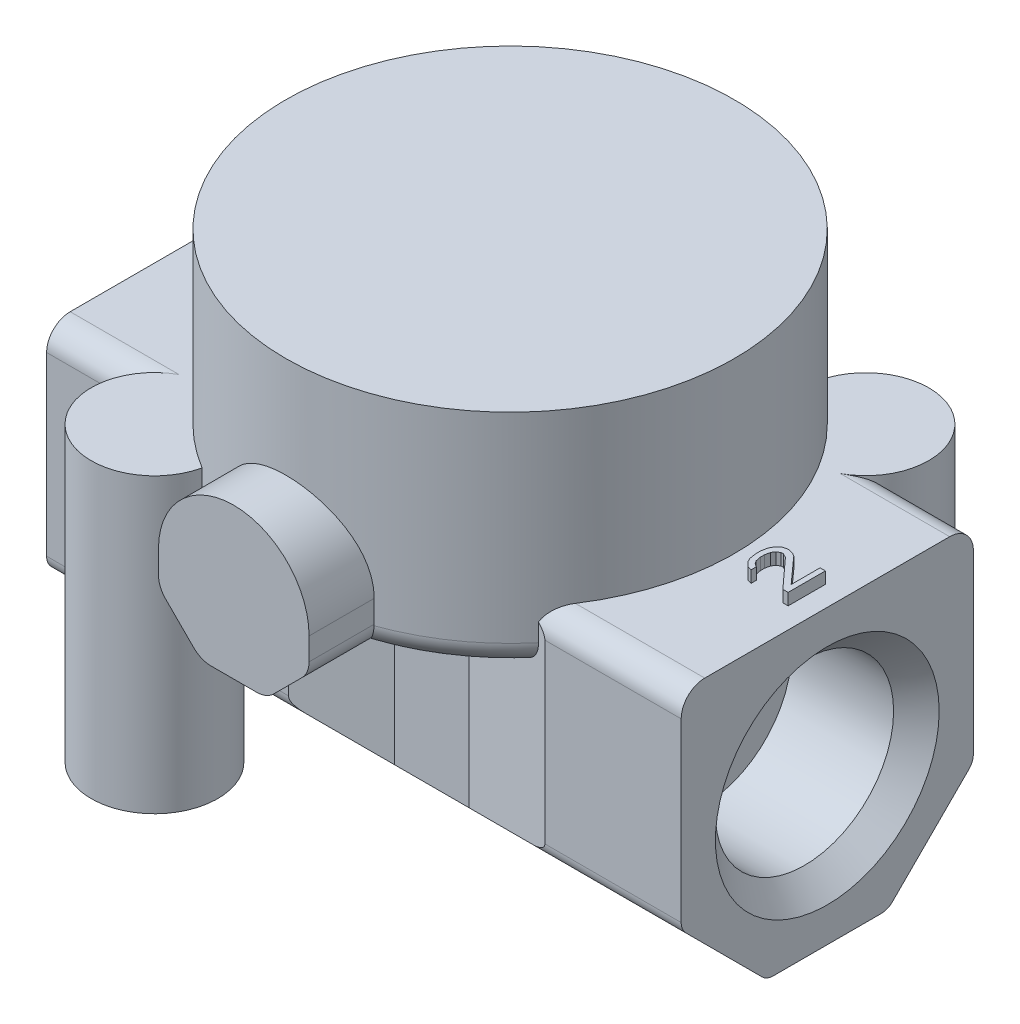
from build123d import *

# Parameters (mm, degrees)
BOSS_EXTRUDE1_DEPTH      = 39.612
CUT_EXTRUDE1_DEPTH       = 5.547196
CUT_EXTRUDE1_DEPTH_BACK  = 5.547196
SKETCH3_W                = 84.337272
SKETCH3_H                = 65.415448
CUT_EXTRUDE2_DEPTH       = 8.27616
CUT_EXTRUDE2_DEPTH_BACK  = 8.27616
SKETCH5_R                = 3.95
BOSS_EXTRUDE2_DEPTH      = 18.269694
BOSS_EXTRUDE3_DEPTH      = 20
SKETCH7_R                = 3.937
BOSS_EXTRUDE4_DEPTH      = 18.269694
BOSS_EXTRUDE5_DEPTH      = 0.7
BOSS_EXTRUDE5_DEPTH_BACK = 0.7
BOSS_EXTRUDE6_DEPTH      = 0.7
BOSS_EXTRUDE6_DEPTH_BACK = 0.7


with BuildPart() as part:
    # Sketch1 → Boss-Extrude1 (new body)
    with BuildSketch(Plane(origin=(19.8, 0, 0), x_dir=(0, 0, -1), z_dir=(1, 0, 0))):
        with BuildLine():
            Line((-8.826801, -4.086395), (-4.070394, -8.842802))
            ThreePointArc((-4.070394, -8.842802), (-3.745971, -9.059574), (-3.363288, -9.135695))
            Line((-3.363288, -9.135695), (3.363288, -9.135695))
            ThreePointArc((3.363288, -9.135695), (3.745971, -9.059574), (4.070395, -8.842801))
            Line((4.070395, -8.842801), (8.826802, -4.086394))
            ThreePointArc((8.826802, -4.086394), (9.043574, -3.761971), (9.119695, -3.379287))
            Line((9.119695, -3.379287), (9.119694, 7.624))
            ThreePointArc((9.119694, 7.624), (8.686302, 8.670302), (7.64, 9.103694))
            Line((7.64, 9.103694), (-7.65, 9.103694))
            ThreePointArc((-7.65, 9.103694), (-8.68923, 8.673231), (-9.119694, 7.634))
            Line((-9.119694, 7.634), (-9.119695, -3.379288))
            ThreePointArc((-9.119695, -3.379288), (-9.043574, -3.761971), (-8.826801, -4.086395))
        make_face()
    extrude(amount=-BOSS_EXTRUDE1_DEPTH)

    # Sketch2 → Cut-Extrude1 (cut, two sides)
    with BuildSketch(Plane.XY) as cut_extrude1_sk:
        Polygon((-11.4, -16.447815), (11.4, -16.447815), (11.4, -9.166), (4.8, -7.366), (-4.8, -7.366), (-11.4, -9.166), align=None)
    extrude(amount=CUT_EXTRUDE1_DEPTH, mode=Mode.SUBTRACT)
    extrude(cut_extrude1_sk.sketch, amount=-CUT_EXTRUDE1_DEPTH_BACK, mode=Mode.SUBTRACT)

    # Sketch3 → Cut-Extrude2 (cut, two sides)
    with BuildSketch(Plane(origin=(0, 0, 0), x_dir=(1, 0, 0), z_dir=(0, 1, 0))) as cut_extrude2_sk:
        with Locations((0.851815, -0.975045)):
            Rectangle(SKETCH3_W, SKETCH3_H)
        Polygon((-26.15286, 16.921805), (-26.15286, -16.921805), (0.145459, -7.35), (4.8, -7.35), (30.199192, -14.277052), (30.199192, 14.277052), (4.8, 7.35), (0.145459, 7.35), align=None, mode=Mode.SUBTRACT)
    extrude(amount=CUT_EXTRUDE2_DEPTH, mode=Mode.SUBTRACT)
    extrude(cut_extrude2_sk.sketch, amount=-CUT_EXTRUDE2_DEPTH_BACK, mode=Mode.SUBTRACT)

    # Sketch4 → Revolve1 (revolve)
    with BuildSketch(Plane(origin=(0, 0, 0), x_dir=(0, 0, -1), z_dir=(1, 0, 0))):
        with BuildLine():
            Line((0, 19.65), (14, 19.65))
            Line((14, 19.65), (14, 7.15))
            ThreePointArc((14, 7.15), (13.56066, 6.08934), (12.5, 5.65))
            Line((12.5, 5.65), (0, 5.65))
            Line((0, 5.65), (0, 19.65))
        make_face()
    revolve(axis=Axis((0, 5.65, 0), (0, 1, 0)))

    # Sketch5 → Boss-Extrude2 (add)
    with BuildSketch(Plane(origin=(0, -9.166, 0), x_dir=(-1, 0, 0), z_dir=(0, -1, 0))):
        with Locations((11.1, -11.1)):
            Circle(SKETCH5_R)
    extrude(amount=-BOSS_EXTRUDE2_DEPTH)

    # Sketch6 → Boss-Extrude3 (add)
    with BuildSketch(Plane.XY.offset(17.25)):
        with BuildLine():
            Line((-4.7, 8.63), (-4.7, 7.231261))
            ThreePointArc((-4.7, 7.231261), (-4.583992, 6.648052), (-4.253631, 6.153631))
            Line((-4.253631, 6.153631), (-2.496369, 4.396369))
            ThreePointArc((-2.496369, 4.396369), (-2.001948, 4.066008), (-1.418739, 3.95))
            Line((-1.418739, 3.95), (1.418739, 3.95))
            ThreePointArc((1.418739, 3.95), (2.001948, 4.066008), (2.496369, 4.396369))
            Line((2.496369, 4.396369), (4.253631, 6.153631))
            ThreePointArc((4.253631, 6.153631), (4.583992, 6.648052), (4.7, 7.231261))
            Line((4.7, 7.231261), (4.7, 8.63))
            ThreePointArc((4.7, 8.63), (0, 13.350043), (-4.7, 8.63))
        make_face()
    extrude(amount=-BOSS_EXTRUDE3_DEPTH)

    # Sketch7 → Boss-Extrude4 (add)
    with BuildSketch(Plane(origin=(0, -9.166, 0), x_dir=(-1, 0, 0), z_dir=(0, -1, 0))):
        with Locations((-11.1, 11.1)):
            Circle(SKETCH7_R)
    extrude(amount=-BOSS_EXTRUDE4_DEPTH)

    # Sketch8 → Boss-Extrude5 (add, two sides)
    with BuildSketch(Plane(origin=(0, 9.134, 0), x_dir=(1, 0, 0), z_dir=(0, 1, 0))) as boss_extrude5_sk:
        Polygon((-15.2, -0.265), (-15.2, 0.1225), (-15.661702, 0.51), (-16.189362, 0.51), (-15.72766, 0.1225), (-18.3, 0.1225), (-18.3, -0.265), align=None)
    extrude(amount=BOSS_EXTRUDE5_DEPTH)
    extrude(boss_extrude5_sk.sketch, amount=-BOSS_EXTRUDE5_DEPTH_BACK)

    # Sketch9 → Boss-Extrude6 (add, two sides)
    with BuildSketch(Plane(origin=(0, 9.134, 0), x_dir=(1, 0, 0), z_dir=(0, 1, 0))) as boss_extrude6_sk:
        Polygon((18.5, -1.143), (18.5, 1.182), (18.170213, 1.182), (18.170213, -0.626333), (16.719149, 0.98825), (16.521277, 1.117417), (16.257447, 1.182), (16.125532, 1.182), (15.861702, 1.117417), (15.597872, 0.859083), (15.465957, 0.60075), (15.4, 0.21325), (15.4, -0.045083), (15.465957, -0.497167), (15.597872, -0.7555), (15.861702, -1.013833), (16.125532, -1.078417), (16.125532, -0.7555), (15.92766, -0.626333), (15.795745, -0.432583), (15.729787, -0.109667), (15.729787, 0.148667), (15.795745, 0.471583), (15.92766, 0.665333), (16.125532, 0.7945), (16.257447, 0.7945), (16.521277, 0.665333), (18.170213, -1.143), align=None)
    extrude(amount=BOSS_EXTRUDE6_DEPTH)
    extrude(boss_extrude6_sk.sketch, amount=-BOSS_EXTRUDE6_DEPTH_BACK)

    # Sketch10 → Cut-Revolve1 (revolve, cut)
    with BuildSketch(Plane(origin=(0, 0, -11.1), x_dir=(-1, 0, 0), z_dir=(0, 0, -1))):
        Polygon((-11.1125, -9.166), (-13.97, -9.166), (-13.208, -8.404), (-13.208, 0.484), (-11.1125, 1.743103), align=None)
    revolve(axis=Axis((11.1125, 1.743207, -11.1), (0, -1, 0)), mode=Mode.SUBTRACT)

    # Sketch11 → Cut-Revolve2 (revolve, cut)
    with BuildSketch(Plane(origin=(0, 0, 11.1), x_dir=(-1, 0, 0), z_dir=(0, 0, -1))):
        Polygon((11.1125, -9.166), (8.317, -9.166), (9.0455, -8.4375), (9.0455, 0.501125), (11.1125, 1.743103), align=None)
    revolve(axis=Axis((-11.1125, 1.743207, 11.1), (0, -1, 0)), mode=Mode.SUBTRACT)

    # Sketch12 → Cut-Revolve3 (revolve, cut)
    with BuildSketch(Plane(origin=(0, 0, 0), x_dir=(-1, 0, 0), z_dir=(0, 0, -1))):
        Polygon((12, 0), (12, 5.4991), (18.3111, 5.4991), (19.812, 7), (19.812, 0), align=None)
    revolve(axis=Axis((-19.812, 0, 0), (1, 0, 0)), mode=Mode.SUBTRACT)

    # Sketch13 → Cut-Revolve4 (revolve, cut)
    with BuildSketch(Plane(origin=(0, 0, 0), x_dir=(-1, 0, 0), z_dir=(0, 0, -1))):
        Polygon((-19.8, 0), (-19.8, 6.985), (-18.3776, 5.5626), (-12, 5.5626), (-12, 0), align=None)
    revolve(axis=Axis((12, 0, 0), (1, 0, 0)), mode=Mode.SUBTRACT)


solid = part.part
